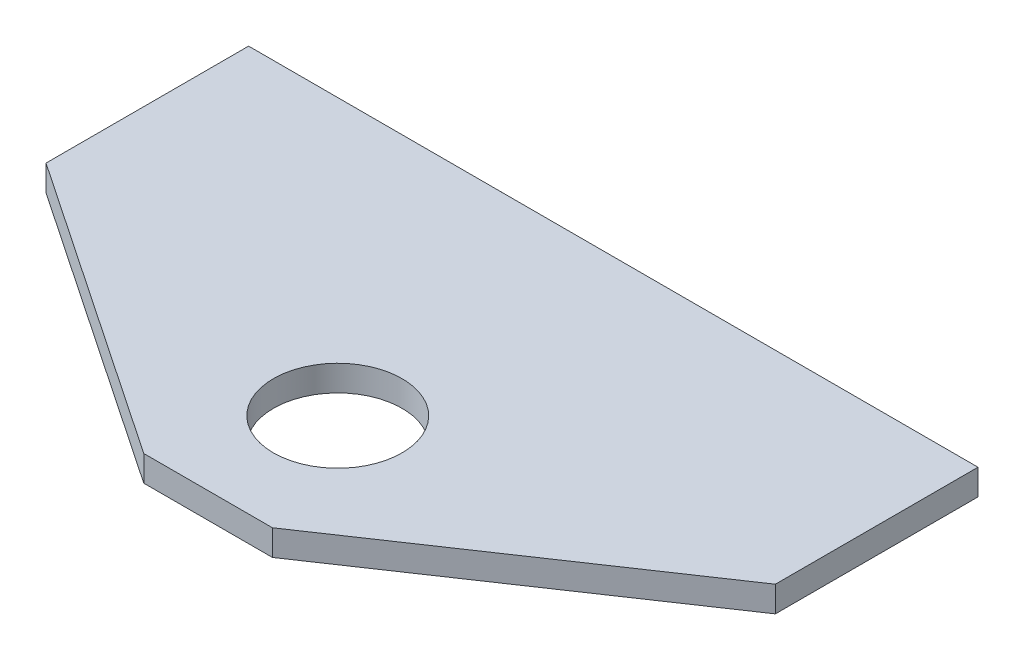
from build123d import *

# Parameters (mm, degrees)
SKETCH2_R       = 3.96875
CONNECTOR_DEPTH = 1.5875


with BuildPart() as part:
    # Sketch2 → Connector (new body)
    with BuildSketch(Plane(origin=(0, 0, 0), x_dir=(1, 0, 0), z_dir=(0, 1, 0))):
        Polygon((22.5, 0), (-22.5, 0), (-22.5, -12.5), (-3.96875, -25), (3.96875, -25), (22.5, -12.5), align=None)
        with Locations((0, -17)):
            Circle(SKETCH2_R, mode=Mode.SUBTRACT)
    extrude(amount=CONNECTOR_DEPTH)


solid = part.part
